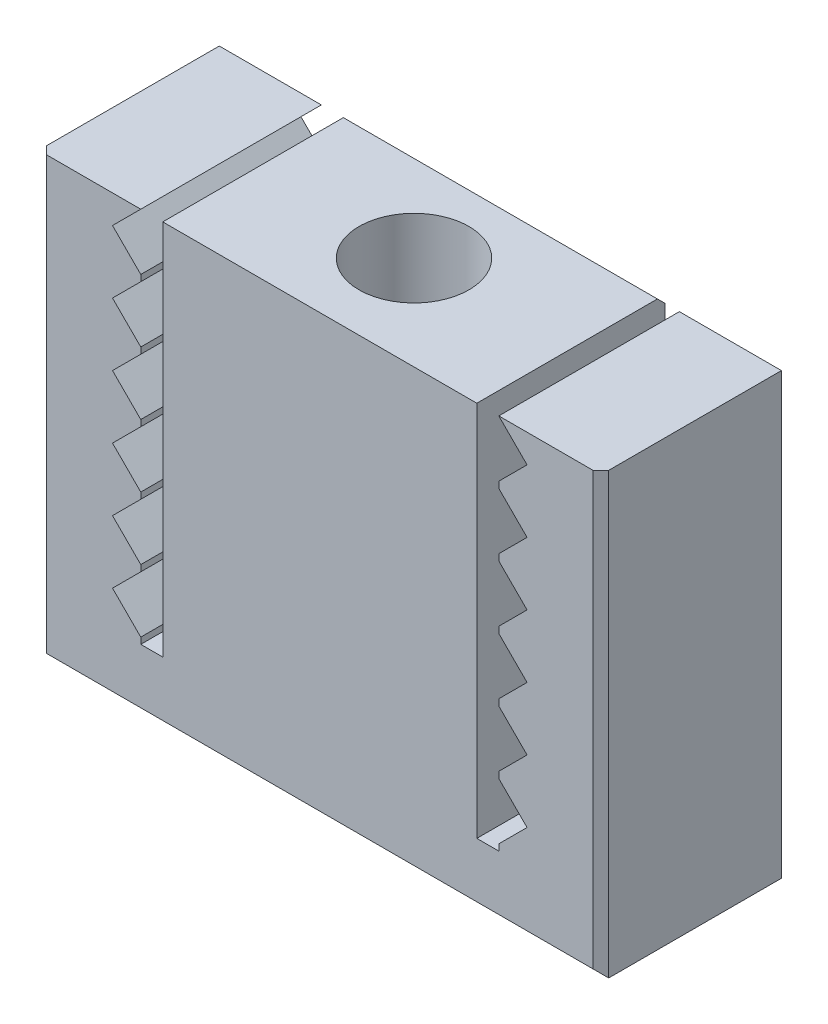
from build123d import *

# Parameters (mm, degrees)
SKETCH1_W           = 17.9
SKETCH1_H           = 14
BOSS_EXTRUDE1_DEPTH = 6
SKETCH2_R           = 1.75
CUT_EXTRUDE1_DEPTH  = 15
CUT_EXTRUDE2_DEPTH  = 6
CHAMFER1_SIZE       = 0.25


with BuildPart() as part:
    # Sketch1 → Boss-Extrude1 (new body)
    with BuildSketch(Plane.XY):
        with Locations((0, 7)):
            Rectangle(SKETCH1_W, SKETCH1_H)
    extrude(amount=BOSS_EXTRUDE1_DEPTH)

    # Sketch2 → Cut-Extrude1 (cut, through all)
    with BuildSketch(Plane(origin=(0, 14, 0), x_dir=(1, 0, 0), z_dir=(0, 1, 0))):
        with Locations((0, -3)):
            Circle(SKETCH2_R)
    extrude(amount=-CUT_EXTRUDE1_DEPTH, mode=Mode.SUBTRACT)

    # Sketch3 → Cut-Extrude2 (cut)
    with BuildSketch(Plane.XY.offset(6)):
        Polygon((5, 14), (5, 2), (5.7, 2), (5.7, 2.2), (6.6, 3.1), (5.7, 4), (5.7, 4.2), (6.6, 5.1), (5.7, 6), (5.7, 6.2), (6.6, 7.1), (5.7, 8), (5.7, 8.2), (6.6, 9.1), (5.7, 10), (5.7, 10.2), (6.6, 11.1), (5.7, 12), (5.7, 12.2), (6.6, 13.1), (5.7, 14), align=None)
        Polygon((-5.7, 2.2), (-5.7, 2), (-5, 2), (-5, 14), (-5.7, 14), (-6.6, 13.1), (-5.7, 12.2), (-5.7, 12), (-6.6, 11.1), (-5.7, 10.2), (-5.7, 10), (-6.6, 9.1), (-5.7, 8.2), (-5.7, 8), (-6.6, 7.1), (-5.7, 6.2), (-5.7, 6), (-6.6, 5.1), (-5.7, 4.2), (-5.7, 4), (-6.6, 3.1), align=None)
    extrude(amount=-CUT_EXTRUDE2_DEPTH, mode=Mode.SUBTRACT)

    # Chamfer1
    chamfer1_edges = [part.edges().sort_by_distance(p)[0] for p in [
        (8.95, 7, 6),
        (0, 14, 0),
        (-7.325, 14, 0),
        (-8.95, 7, 6),
        (7.325, 14, 0),
        (8.95, 7, 0),
        (0, 0, 0),
        (-8.95, 7, 0),
        (0, 0, 6),
    ]]
    chamfer(chamfer1_edges, length=CHAMFER1_SIZE)


solid = part.part
